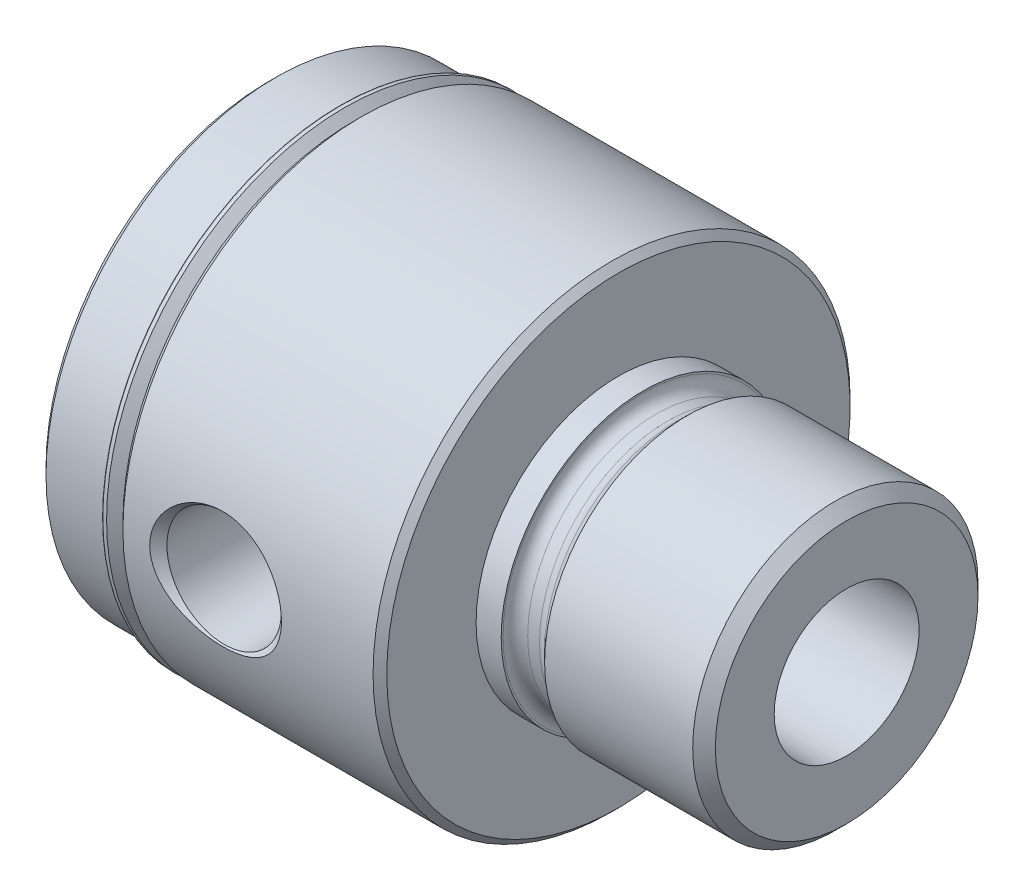
from build123d import *

# Parameters (mm, degrees)
SKETCH5_W = 73.9394
SKETCH5_H = 8.0645


with BuildPart() as part:
    # Sketch1 → Revolve1 (revolve)
    with BuildSketch(Plane.XY):
        Polygon((-38.8874, 0), (-38.8874, 24.8158), (-38.1254, 25.5778), (-31.496, 25.5778), (-30.4292, 24.511), (-29.3624, 24.511), (-29.3624, 25.781), (-28.6004, 26.543), (-0.762, 26.543), (0, 25.781), (0, 0), align=None)
    revolve(axis=Axis((0, 0, 0), (-1, 0, 0)))

    # Sketch2 → Revolve2 (revolve)
    with BuildSketch(Plane.XY):
        with BuildLine():
            Line((0, 0), (0, 15.84325))
            Line((0, 15.84325), (2.794, 15.84325))
            Line((2.794, 15.84325), (2.794, 15.6337))
            ThreePointArc((2.794, 15.6337), (3.195732339, 14.663832339), (4.1656, 14.2621))
            Line((4.1656, 14.2621), (5.477064678, 14.2621))
            ThreePointArc((5.477064678, 14.2621), (6.001953274, 14.366506833), (6.446932339, 14.663832339))
            Line((6.446932339, 14.663832339), (7.6581, 15.875))
            Line((7.6581, 15.875), (24.14016, 15.875))
            Line((24.14016, 15.875), (25.4, 14.61516))
            Line((25.4, 14.61516), (25.4, 0))
            Line((25.4, 0), (0, 0))
        make_face()
    revolve(axis=Axis((25.4, 0, 0), (-1, 0, 0)))

    # Sketch3 → Cut-Revolve1 (revolve, cut)
    with BuildSketch(Plane(origin=(0, 0, 0), x_dir=(1, 0, 0), z_dir=(0, 1, 0))):
        Polygon((-18.288, 0), (-12.612335918, -3.276846186), (-11.915865896, -25.585630358), (-10.958496254, -26.543), (-10.958496254, -29.083), (-18.288, -29.083), align=None)
    revolve(axis=Axis((-18.288, 0, 29.083), (0, 0, -1)), mode=Mode.SUBTRACT)

    # Sketch4 → Revolve3 (revolve)
    with BuildSketch(Plane.XY):
        with BuildLine():
            Line((-30.94380107, 26.318757951), (-28.812753898, 24.18771078))
            Line((-28.812753898, 24.18771078), (-28.489464678, 24.511))
            Line((-28.489464678, 24.511), (-30.470664678, 26.4922))
            Line((-30.470664678, 26.4922), (-30.871959021, 26.4922))
            ThreePointArc((-30.871959021, 26.4922), (-30.965825181, 26.429480637), (-30.94380107, 26.318757951))
        make_face()
    revolve(axis=Axis((-30.470664678, 0, 0), (-1, 0, 0)))

    # Sketch5 → Cut-Revolve2 (revolve, cut)
    with BuildSketch(Plane.XY):
        with Locations((-1.9177, 4.03225)):
            Rectangle(SKETCH5_W, SKETCH5_H)
    revolve(axis=Axis((35.052, 0, 0), (-1, 0, 0)), mode=Mode.SUBTRACT)


solid = part.part
